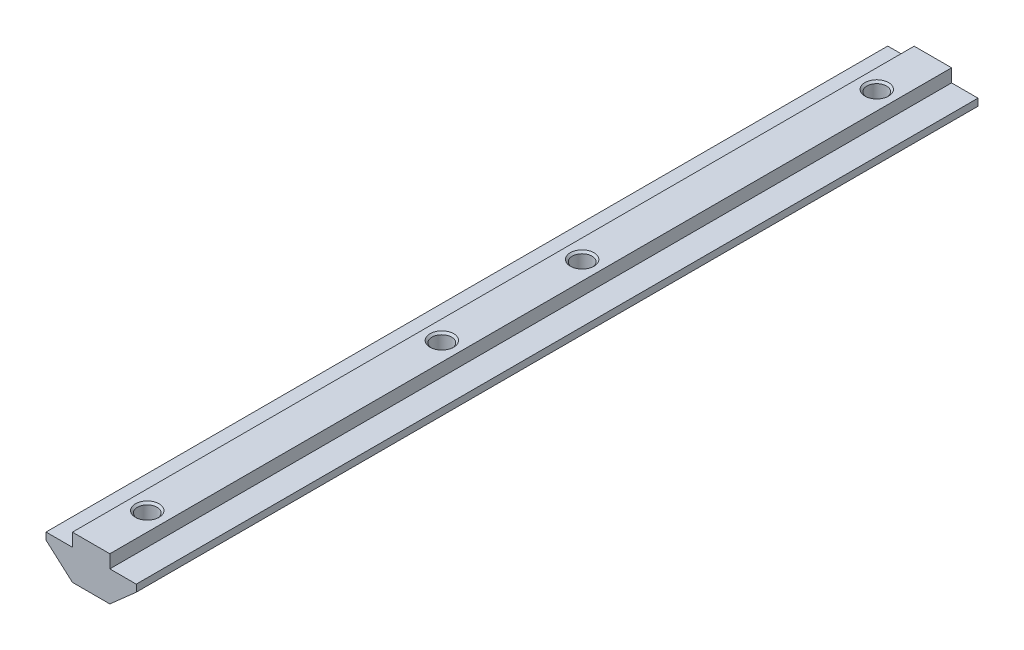
from build123d import *

# Parameters (mm, degrees)
EXTRUDE_1_DEPTH            = 90
HOLE_WIZARD_M52_AT_2_COUNT = 2
HOLE_WIZARD_M52_AT_2_PITCH = 63
HOLE_WIZARD_M52_AT_3_COUNT = 2
HOLE_WIZARD_M52_AT_3_PITCH = 93
HOLE_WIZARD_M52_AT_4_COUNT = 2
HOLE_WIZARD_M52_AT_4_PITCH = 156


with BuildPart() as part:
    # Эскиз1 → Бобышка-Вытянуть1 (new body, symmetric)
    with BuildSketch(Plane.XY):
        Polygon((4, 0), (-4, 0), (-4, -2.8), (-9.65, -2.8), (-9.65, -4.3), (-4, -9.3), (4, -9.3), (9.65, -4.3), (9.65, -2.8), (4, -2.8), align=None)
    extrude(amount=EXTRUDE_1_DEPTH, both=True)

    # Эскиз6 → Отверстие обработанное метчиком M52 (revolve, cut)
    with BuildSketch(Plane(origin=(0, 0, -78), x_dir=(0, 0, 1), z_dir=(1, 0, 0))):
        Polygon((0, 0), (0, 9.3), (2.525, 9.3), (2.1, 8.875), (2.1, 0.425), (2.525, 0), align=None)
    hole_wizard_m52 = revolve(axis=Axis((0, 6.35, -78), (0, -1, 0)), mode=Mode.SUBTRACT)

    # Отверстие обработанное метчиком M52 at 2: Отверстие обработанное метчиком M52 ×2
    with Locations(*[(0, 0, i * HOLE_WIZARD_M52_AT_2_PITCH) for i in range(1, HOLE_WIZARD_M52_AT_2_COUNT)]):
        add(hole_wizard_m52, mode=Mode.SUBTRACT)

    # Отверстие обработанное метчиком M52 at 3: Отверстие обработанное метчиком M52 ×2
    with Locations(*[(0, 0, i * HOLE_WIZARD_M52_AT_3_PITCH) for i in range(1, HOLE_WIZARD_M52_AT_3_COUNT)]):
        add(hole_wizard_m52, mode=Mode.SUBTRACT)

    # Отверстие обработанное метчиком M52 at 4: Отверстие обработанное метчиком M52 ×2
    with Locations(*[(0, 0, i * HOLE_WIZARD_M52_AT_4_PITCH) for i in range(1, HOLE_WIZARD_M52_AT_4_COUNT)]):
        add(hole_wizard_m52, mode=Mode.SUBTRACT)


solid = part.part
